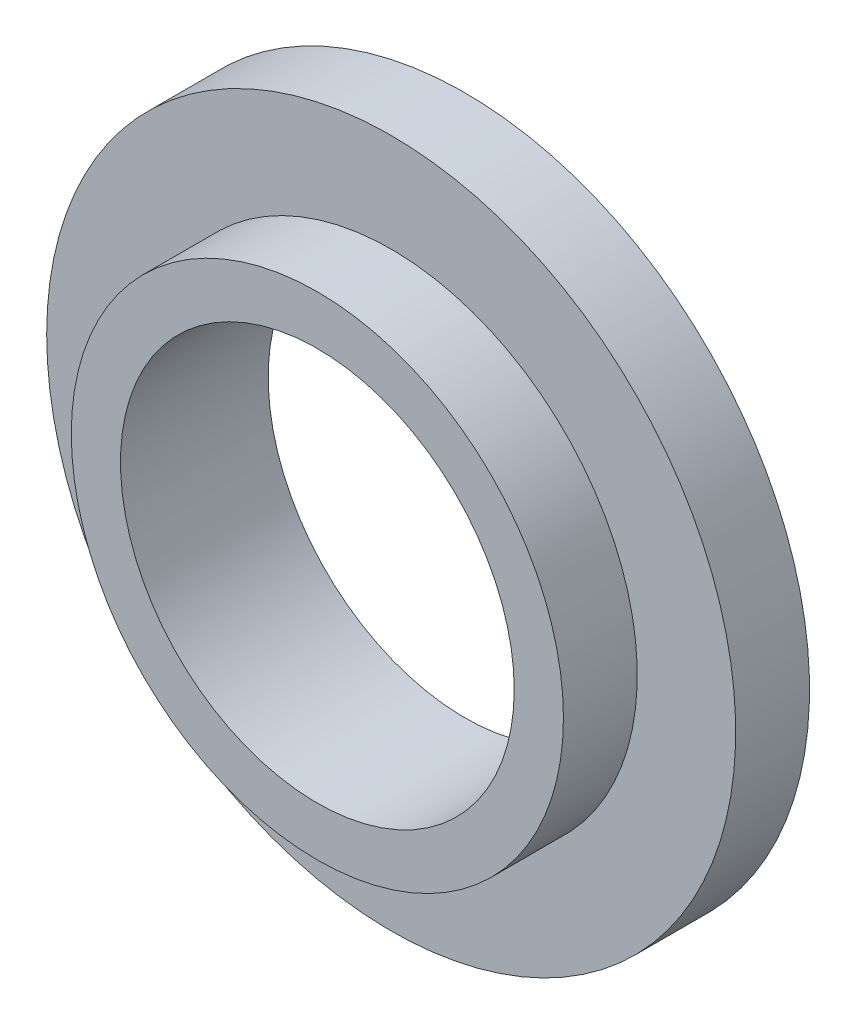
from build123d import *

# Parameters (mm, degrees)
SKETCH1_R           = 25
SKETCH1_R_2         = 20
BOSS_EXTRUDE1_DEPTH = 15
SKETCH2_R           = 35
SKETCH2_R_2         = 25
BOSS_EXTRUDE2_DEPTH = 7.5


with BuildPart() as part:
    # Sketch1 → Boss-Extrude1 (new body)
    with BuildSketch(Plane.XY):
        Circle(SKETCH1_R)
        Circle(SKETCH1_R_2, mode=Mode.SUBTRACT)
    extrude(amount=BOSS_EXTRUDE1_DEPTH)

    # Sketch2 → Boss-Extrude2 (add)
    with BuildSketch(Plane(origin=(0, 0, 0), x_dir=(-1, 0, 0), z_dir=(0, 0, -1))):
        Circle(SKETCH2_R)
        Circle(SKETCH2_R_2, mode=Mode.SUBTRACT)
    extrude(amount=-BOSS_EXTRUDE2_DEPTH)


solid = part.part
